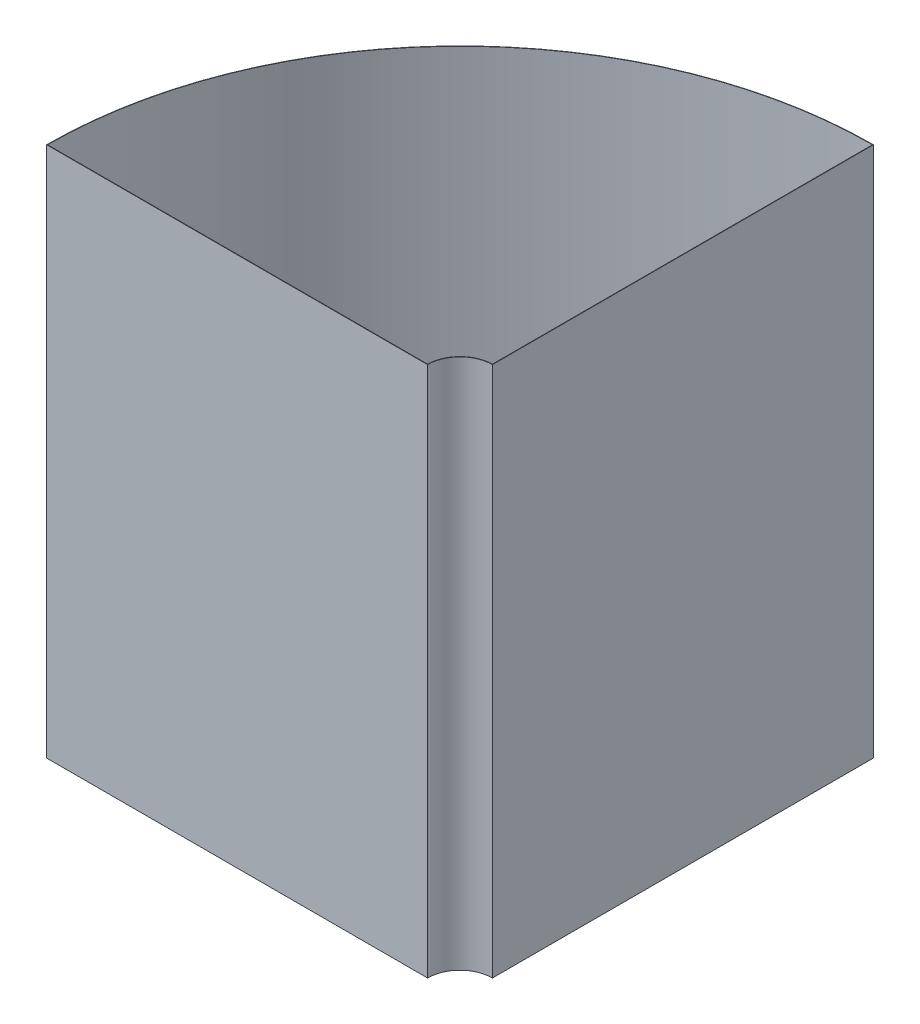
from build123d import *

# Parameters (mm, degrees)
BOSS_EXTRUDE1_DEPTH = 450
SHELL1_T            = -0.35


with BuildPart() as part:
    # Sketch1 → Boss-Extrude1 (new body)
    with BuildSketch(Plane(origin=(0, 0, 0), x_dir=(1, 0, 0), z_dir=(0, 1, 0))):
        with BuildLine():
            Line((-350.175, 0), (-27.5, 0))
            ThreePointArc((-27.5, 0), (-19.445436483, 19.445436483), (0, 27.5))
            Line((0, 27.5), (0, 350.175))
            ThreePointArc((0, 350.175), (-247.611117102, 247.611117102), (-350.175, 0))
        make_face()
    extrude(amount=BOSS_EXTRUDE1_DEPTH)

    # Shell1
    shell1_openings = [part.faces().sort_by_distance(p)[0] for p in [
        (-113.973513396, 450, -113.973513396),
    ]]
    offset(amount=SHELL1_T, openings=shell1_openings, kind=Kind.INTERSECTION)


solid = part.part
